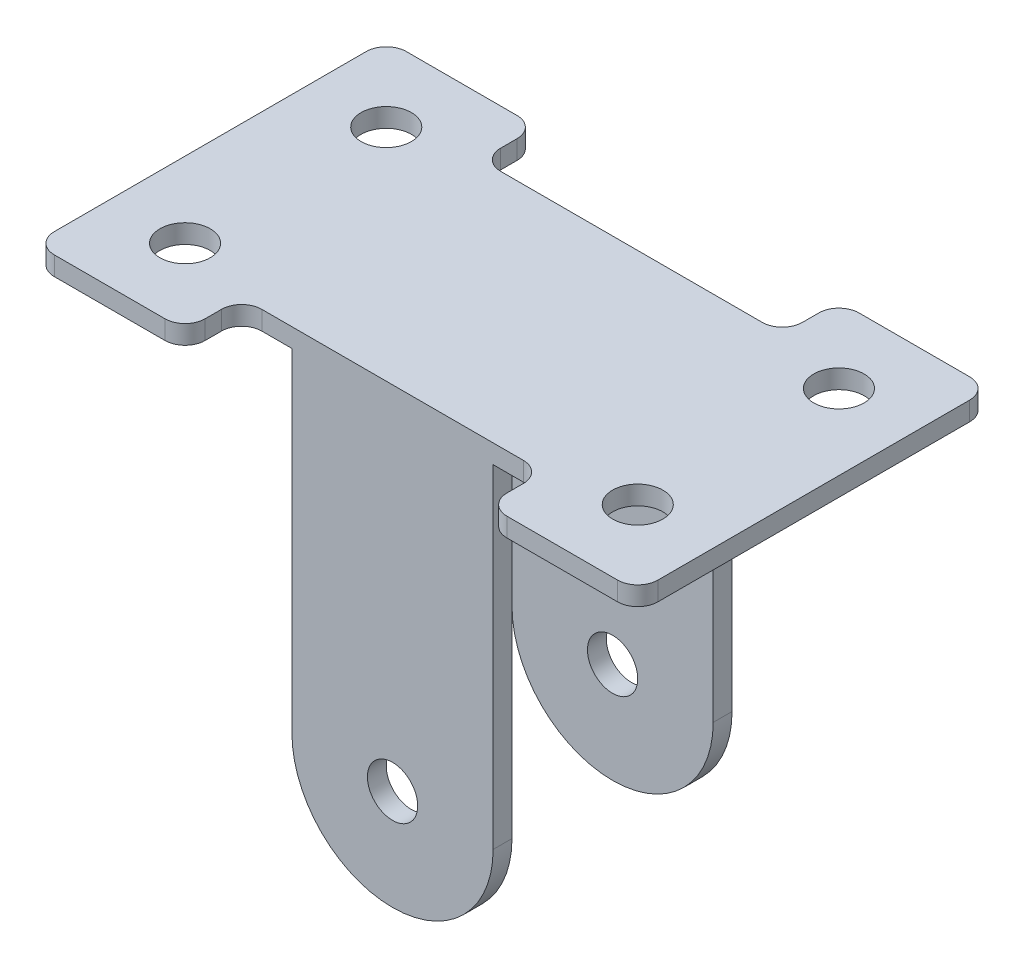
from build123d import *

# Parameters (mm, degrees)
SKETCH1_W           = 76.2
SKETCH1_H           = 44.45
BOSS_EXTRUDE1_DEPTH = 2.38125
SKETCH2_R           = 3.175
CUT_EXTRUDE1_DEPTH  = 2.38125
SKETCH5_W           = 38.1
SKETCH5_H           = 7.14375
CUT_EXTRUDE4_DEPTH  = 2.38125
BOSS_EXTRUDE4_DEPTH = 2.38125
SKETCH7_R           = 3.175
CUT_EXTRUDE5_DEPTH  = 2.38125
FILLET1_R           = 2.54


with BuildPart() as part:
    # Sketch1 → Boss-Extrude1 (new body)
    with BuildSketch(Plane(origin=(0, 0, 0), x_dir=(1, 0, 0), z_dir=(0, 1, 0))):
        Rectangle(SKETCH1_W, SKETCH1_H)
    extrude(amount=BOSS_EXTRUDE1_DEPTH)

    # Sketch2 → Cut-Extrude1 (cut)
    with BuildSketch(Plane(origin=(0, 2.38125, 0), x_dir=(1, 0, 0), z_dir=(0, 1, 0))):
        with Locations(Location((-28.575, -12.7, 0), (0, 0, 270))):  # turned: the seam where the file's is
            Circle(SKETCH2_R)
        with Locations(Location((-28.575, 12.7, 0), (0, 0, 270))):  # turned: the seam where the file's is
            Circle(SKETCH2_R)
        with Locations(Location((28.575, 12.7, 0), (0, 0, 270))):  # turned: the seam where the file's is
            Circle(SKETCH2_R)
        with Locations(Location((28.575, -12.7, 0), (0, 0, 270))):  # turned: the seam where the file's is
            Circle(SKETCH2_R)
    extrude(amount=-CUT_EXTRUDE1_DEPTH, mode=Mode.SUBTRACT)

    # Sketch5 → Cut-Extrude4 (cut)
    with BuildSketch(Plane(origin=(0, 2.38125, 0), x_dir=(1, 0, 0), z_dir=(0, 1, 0))):
        with Locations((0, -18.653125)):
            Rectangle(SKETCH5_W, SKETCH5_H)
    cut_extrude4 = extrude(amount=-CUT_EXTRUDE4_DEPTH, mode=Mode.SUBTRACT)

    # Sketch6 → Boss-Extrude4 (add)
    with BuildSketch(Plane.XY.offset(15.08125)):
        with BuildLine():
            Line((-12.7, 2.38125), (12.7, 2.38125))
            Line((12.7, 2.38125), (12.7, -42.06875))
            ThreePointArc((12.7, -42.06875), (0, -54.76875), (-12.7, -42.06875))
            Line((-12.7, -42.06875), (-12.7, 2.38125))
        make_face()
    boss_extrude4 = extrude(amount=-BOSS_EXTRUDE4_DEPTH)

    # Sketch7 → Cut-Extrude5 (cut)
    with BuildSketch(Plane.XY.offset(15.08125)):
        with Locations((0, -42.06875)):
            Circle(SKETCH7_R)
    cut_extrude5 = extrude(amount=-CUT_EXTRUDE5_DEPTH, mode=Mode.SUBTRACT)

    # Mirror2: Cut-Extrude4, Boss-Extrude4, Cut-Extrude5 across plane
    add(cut_extrude4.mirror(Plane.XY), mode=Mode.SUBTRACT)
    add(boss_extrude4.mirror(Plane.XY))
    add(cut_extrude5.mirror(Plane.XY), mode=Mode.SUBTRACT)

    # Fillet1
    fillet1_edges = [part.edges().sort_by_distance(p)[0] for p in [
        (-19.05, 1.190625, 22.225),
        (-19.05, 1.190625, 15.08125),
        (19.05, 1.190625, 15.08125),
        (19.05, 1.190625, 22.225),
        (-38.1, 1.190625, -22.225),
        (38.1, 1.190625, -22.225),
        (-19.05, 1.190625, -15.08125),
        (-19.05, 1.190625, -22.225),
        (19.05, 1.190625, -22.225),
        (38.1, 1.190625, 22.225),
        (19.05, 1.190625, -15.08125),
        (-38.1, 1.190625, 22.225),
    ]]
    fillet(fillet1_edges, radius=FILLET1_R)


solid = part.part
